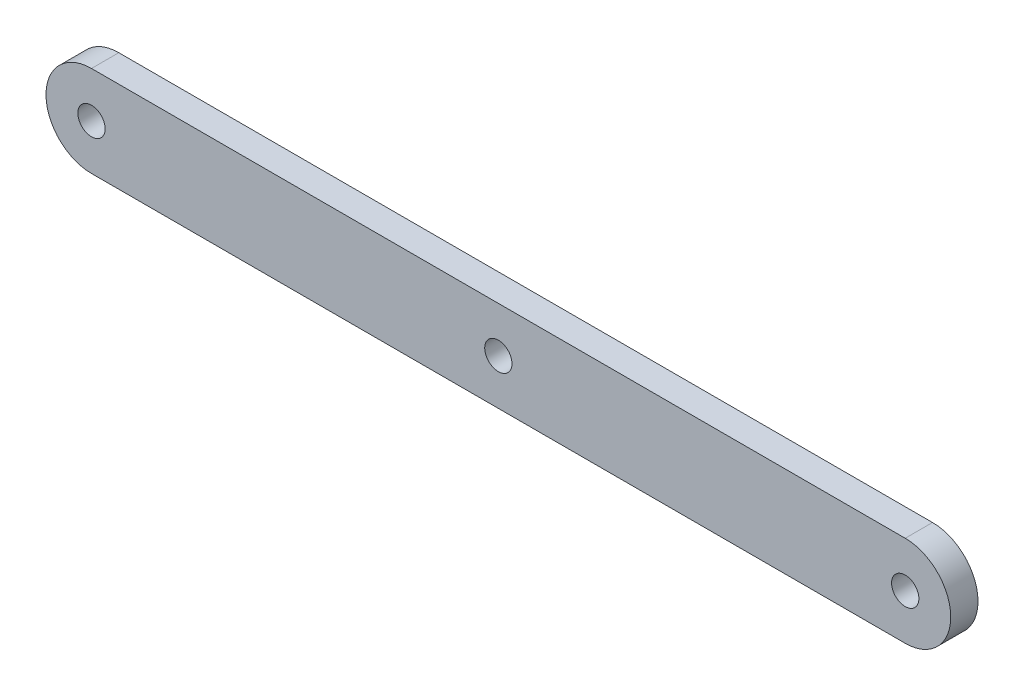
from build123d import *

# Parameters (mm, degrees)
SKETCH_1_R      = 0.75
EXTRUDE_1_DEPTH = 0.75


with BuildPart() as part:
    # 草圖1 → 填料-伸長1 (new body, symmetric)
    with BuildSketch(Plane.XY):
        with BuildLine():
            Line((-22.36, 2.5), (22.36, 2.5))
            ThreePointArc((22.36, 2.5), (24.86, 0), (22.36, -2.5))
            Line((22.36, -2.5), (-22.36, -2.5))
            ThreePointArc((-22.36, -2.5), (-24.86, 0), (-22.36, 2.5))
        make_face()
        with Locations((22.36, 0)):
            Circle(SKETCH_1_R, mode=Mode.SUBTRACT)
        with Locations((-22.36, 0)):
            Circle(SKETCH_1_R, mode=Mode.SUBTRACT)
        Circle(SKETCH_1_R, mode=Mode.SUBTRACT)
    extrude(amount=EXTRUDE_1_DEPTH, both=True)


solid = part.part
